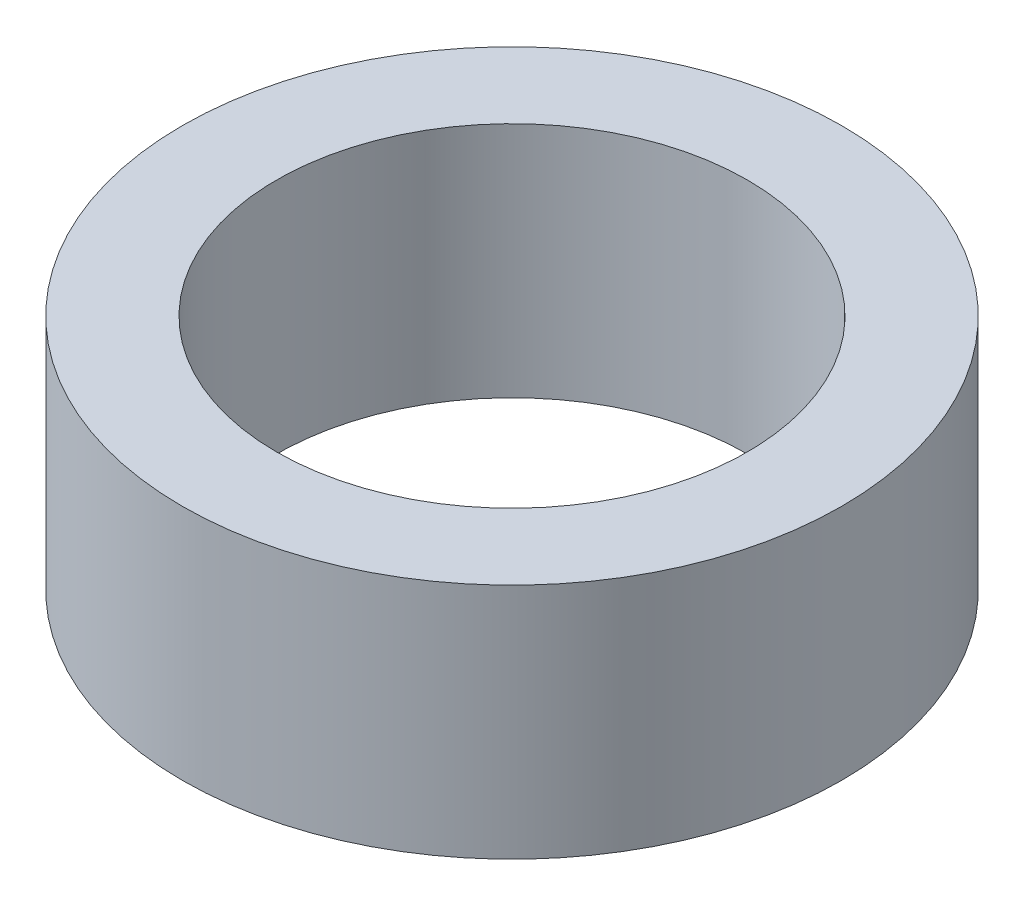
from build123d import *

# Parameters (mm, degrees)
SKETCH_1_R      = 2.2225
SKETCH_1_R_2    = 1.5875
EXTRUDE_1_DEPTH = 1.6


with BuildPart() as part:
    # 草图1 → 凸台-拉伸1 (new body)
    with BuildSketch(Plane(origin=(0, 0, 0), x_dir=(1, 0, 0), z_dir=(0, 1, 0))):
        Circle(SKETCH_1_R)
        Circle(SKETCH_1_R_2, mode=Mode.SUBTRACT)
    extrude(amount=EXTRUDE_1_DEPTH)


solid = part.part
